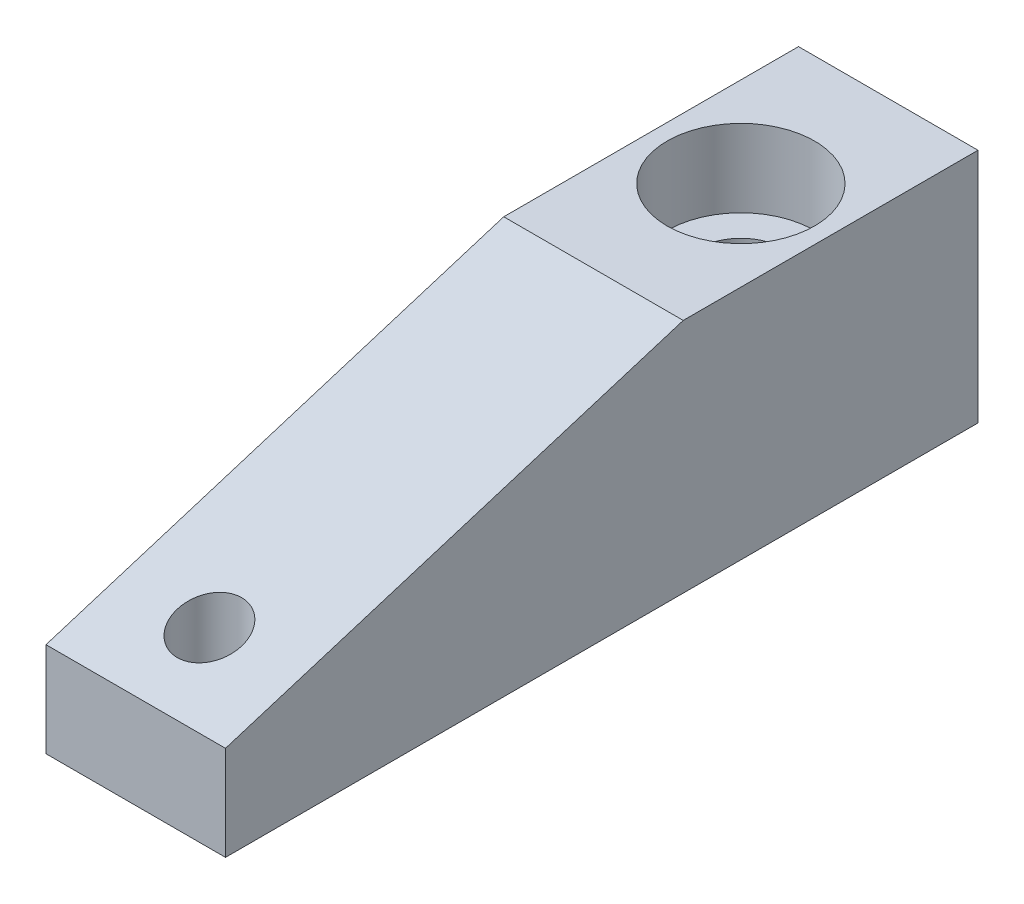
from build123d import *

# Parameters (mm, degrees)
SKETCH1_W          = 9.652
SKETCH1_H          = 40.4622
EXTRUDE1_DEPTH     = 12.7
FILLET1_R          = 0.127
CUT_EXTRUDE1_DEPTH = 10.652
SKETCH5_R          = 1.7272
CUT_EXTRUDE2_DEPTH = 13.7


with BuildPart() as part:
    # Sketch1 → Extrude1 (new body)
    with BuildSketch(Plane(origin=(0, 0, 0), x_dir=(1, 0, 0), z_dir=(0, 1, 0))):
        with Locations((4.826, -20.2311)):
            Rectangle(SKETCH1_W, SKETCH1_H)
    extrude(amount=EXTRUDE1_DEPTH)

    # Sketch3 → Cut-Revolve1 (revolve, cut)
    with BuildSketch(Plane(origin=(4.826, 0, 0), x_dir=(0, 0, -1), z_dir=(1, 0, 0))):
        Polygon((-11.8872, 12.7), (-11.8872, 8.5344), (-10.2108, 8.5344), (-10.2108, 6.6548), (-10.629274995, 6.6548), (-11.0363, 0), (-7.9248, 0), (-7.9248, 12.7), align=None)
    revolve(axis=Axis((4.826, 31.679444444, 7.9248), (0, -1, 0)), mode=Mode.SUBTRACT)

    # Fillet1
    fillet1_edges = [part.edges().sort_by_distance(p)[0] for p in [
        (4.826, 6.6548, 5.220325005),
    ]]
    fillet(fillet1_edges, radius=FILLET1_R)

    # Sketch4 → Cut-Extrude1 (cut, through all)
    with BuildSketch(Plane(origin=(9.652, 0, 0), x_dir=(0, 0, -1), z_dir=(1, 0, 0))):
        Polygon((-40.4622, 5.08), (-40.4622, 12.7), (-15.8496, 12.7), align=None)
    extrude(amount=-CUT_EXTRUDE1_DEPTH, mode=Mode.SUBTRACT)

    # Sketch5 → Cut-Extrude2 (cut, through all)
    with BuildSketch(Plane.XZ):
        with Locations(Location((4.826, 36.4998, 0), (0, 0, 270))):  # turned: the seam where the file's is
            Circle(SKETCH5_R)
    extrude(amount=-CUT_EXTRUDE2_DEPTH, mode=Mode.SUBTRACT)


solid = part.part
